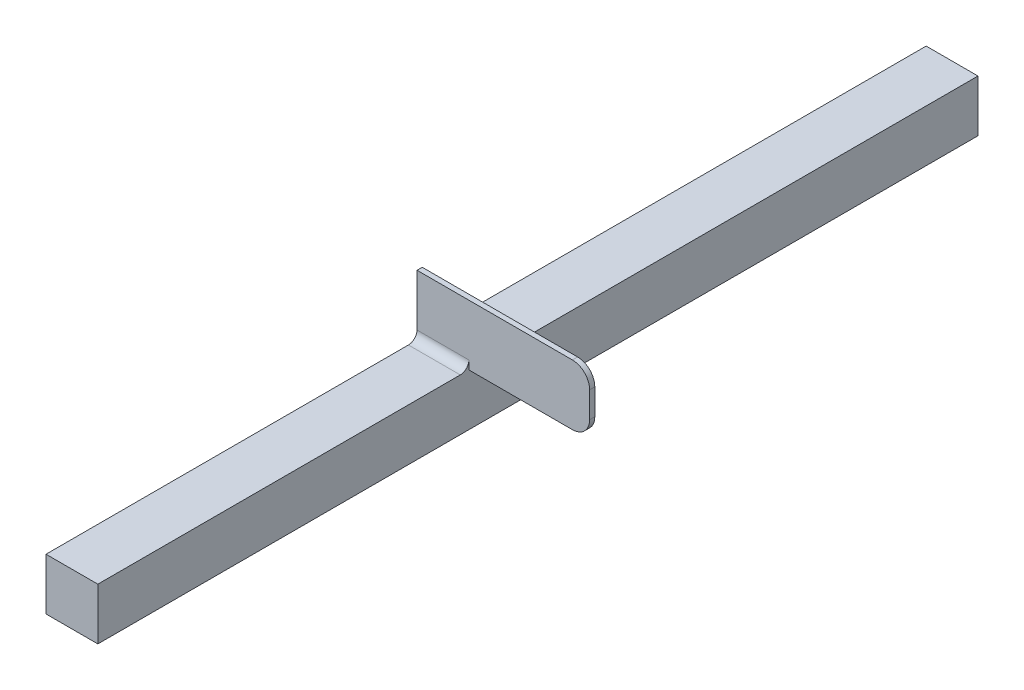
from build123d import *

# Parameters (mm, degrees)
ESBO_O2_W                     = 30.045415171
ESBO_O2_H                     = 30
RESSALTO_EXTRUS_O1_DEPTH      = 255
ESBO_O4_W                     = 100
ESBO_O4_H                     = 35
RESSALTO_EXTRUS_O2_DEPTH      = 0.001
RESSALTO_EXTRUS_O2_DEPTH_BACK = 3
FILETE1_R                     = 5
FILETE2_R                     = 10


with BuildPart() as part:
    # Esboço2 → Ressalto-extrusão1 (new body, symmetric)
    with BuildSketch(Plane.XY):
        with Locations((-95.635568537, 15)):
            Rectangle(ESBO_O2_W, ESBO_O2_H)
    extrude(amount=RESSALTO_EXTRUS_O1_DEPTH, both=True)

    # Esboço4 → Ressalto-extrusão2 (add, two sides)
    with BuildSketch(Plane.XY.offset(40)) as ressalto_extrus_o2_sk:
        with Locations((-60.658276122, 47.5)):
            Rectangle(ESBO_O4_W, ESBO_O4_H)
    extrude(amount=RESSALTO_EXTRUS_O2_DEPTH)
    extrude(ressalto_extrus_o2_sk.sketch, amount=-RESSALTO_EXTRUS_O2_DEPTH_BACK)

    # Filete1
    filete1_edges = [part.edges().sort_by_distance(p)[0] for p in [
        (-95.635568536, 30, 37),
        (-95.635568536, 30, 40.001),
    ]]
    fillet(filete1_edges, radius=FILETE1_R)

    # Filete2
    filete2_edges = [part.edges().sort_by_distance(p)[0] for p in [
        (-10.658276122, 65, 38.5005),
        (-10.658276122, 30, 38.5005),
    ]]
    fillet(filete2_edges, radius=FILETE2_R)


solid = part.part
